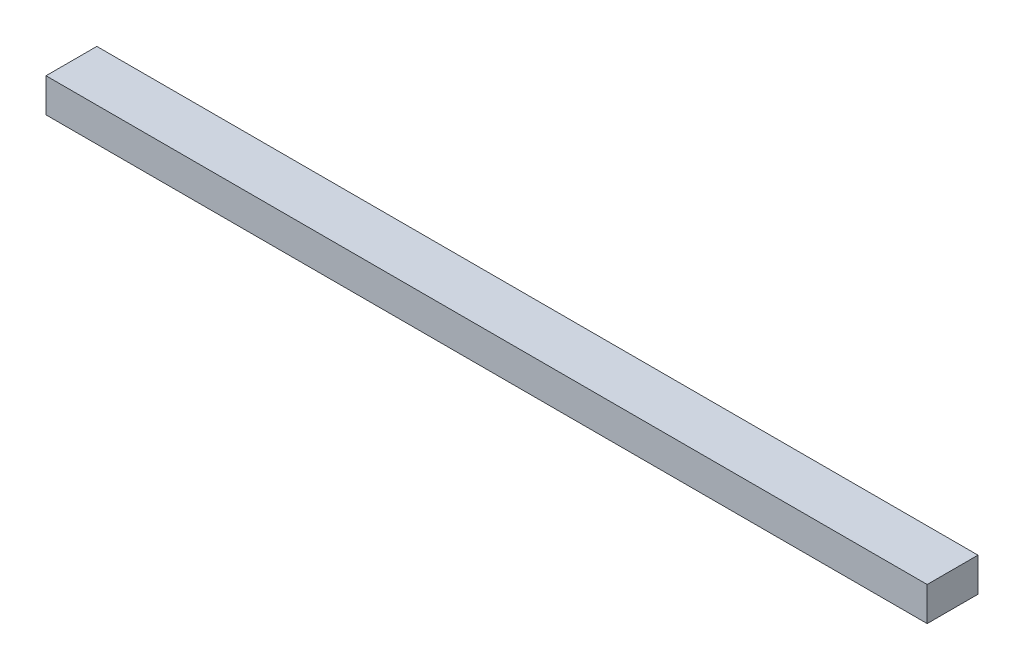
from build123d import *

# Parameters (mm, degrees)
SKETCH1_W           = 52
SKETCH1_H           = 3
BOSS_EXTRUDE1_DEPTH = 2


with BuildPart() as part:
    # Sketch1 → Boss-Extrude1 (new body)
    with BuildSketch(Plane(origin=(0, 0, 0), x_dir=(1, 0, 0), z_dir=(0, 1, 0))):
        with Locations((26, 1.5)):
            Rectangle(SKETCH1_W, SKETCH1_H)
    extrude(amount=BOSS_EXTRUDE1_DEPTH)


solid = part.part
